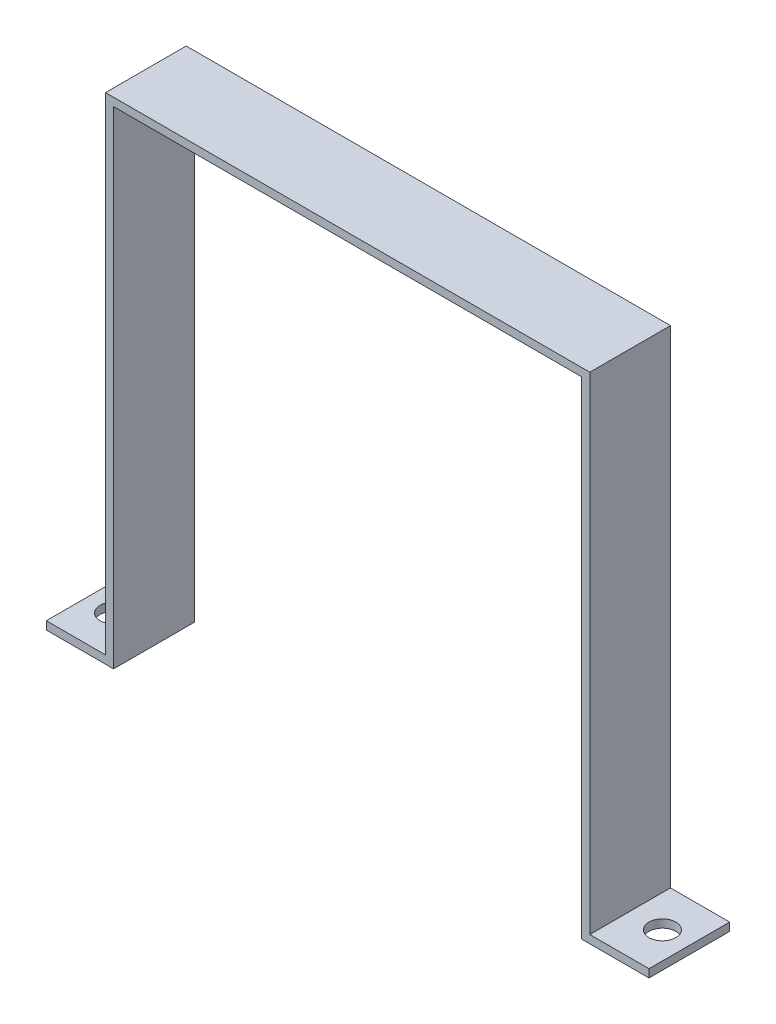
from build123d import *

# Parameters (mm, degrees)
BOSS_EXTRUDE1_DEPTH = 30
SKETCH2_R           = 5
CUT_EXTRUDE1_DEPTH  = 30


with BuildPart() as part:
    # Sketch1 → Boss-Extrude1 (new body)
    with BuildSketch(Plane.XY):
        Polygon((-87, 0), (-87, 181), (87, 181), (87, 0), (112, 0), (112, 3), (90, 3), (90, 184), (-90, 184), (-90, 3), (-112, 3), (-112, 0), align=None)
    extrude(amount=BOSS_EXTRUDE1_DEPTH)

    # Sketch2 → Cut-Extrude1 (cut)
    with BuildSketch(Plane(origin=(0, 3, 0), x_dir=(1, 0, 0), z_dir=(0, 1, 0))):
        with Locations((-102, -15)):
            Circle(SKETCH2_R)
        with Locations((102, -15)):
            Circle(SKETCH2_R)
    extrude(amount=-CUT_EXTRUDE1_DEPTH, mode=Mode.SUBTRACT)


solid = part.part
